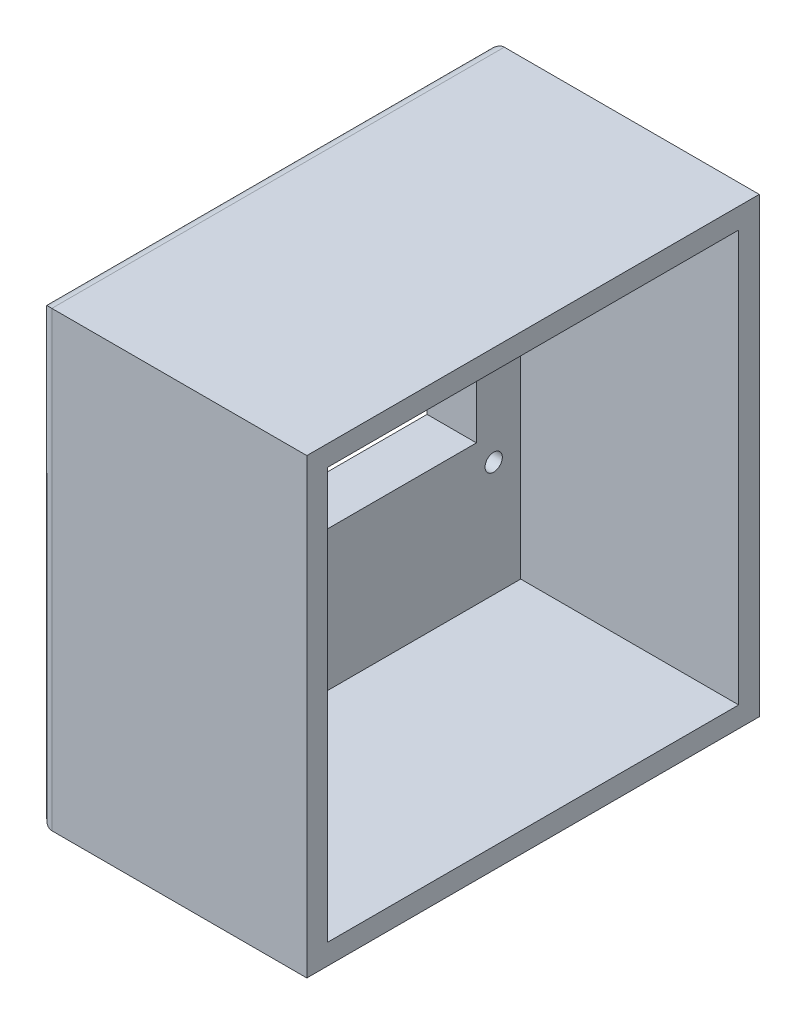
from build123d import *

# Parameters (mm, degrees)
ESBO_O1_W                = 100
ESBO_O1_H                = 100
ESBO_O1_R                = 2.099999731
ESBO_O1_R_2              = 3.499999496
ESBO_O1_R_3              = 3.399999765
RESSALTO_EXTRUS_O1_DEPTH = 12
ESBO_O2_W                = 80
ESBO_O2_H                = 53
CORTE_EXTRUS_O1_DEPTH    = 12
ESBO_O3_W                = 110
ESBO_O3_H                = 110
ESBO_O3_W_2              = 100
ESBO_O3_H_2              = 100
RESSALTO_EXTRUS_O2_DEPTH = 65
FILETE1_R                = 3


with BuildPart() as part:
    # Esboço1 → Ressalto-extrusão1 (new body)
    with BuildSketch(Plane(origin=(0, 0, 0), x_dir=(0, 0, -1), z_dir=(1, 0, 0))):
        with Locations((-414.454548573, 389.240771296)):
            Rectangle(ESBO_O1_W, ESBO_O1_H)
        with Locations((-371.077987612, 432.946200958)):
            Circle(ESBO_O1_R, mode=Mode.SUBTRACT)
        with Locations((-371.024063379, 367.14624515)):
            Circle(ESBO_O1_R, mode=Mode.SUBTRACT)
        with Locations((-458.877958129, 432.87424738)):
            Circle(ESBO_O1_R, mode=Mode.SUBTRACT)
        with Locations((-458.824033895, 367.074291572)):
            Circle(ESBO_O1_R, mode=Mode.SUBTRACT)
        with Locations((-451.165348634, 356.487124133)):
            Circle(ESBO_O1_R_2, mode=Mode.SUBTRACT)
        with Locations((-418.165360481, 356.508431567)):
            Circle(ESBO_O1_R_3, mode=Mode.SUBTRACT)
    extrude(amount=RESSALTO_EXTRUS_O1_DEPTH)

    # Esboço2 → Corte-extrusão1 (cut)
    with BuildSketch(Plane.ZY):
        with Locations((415.220911045, 399.798918519)):
            Rectangle(ESBO_O2_W, ESBO_O2_H)
    extrude(amount=-CORTE_EXTRUS_O1_DEPTH, mode=Mode.SUBTRACT)

    # Esboço3 → Ressalto-extrusão2 (add)
    with BuildSketch(Plane.ZY):
        with Locations((414.454548573, 389.240771296)):
            Rectangle(ESBO_O3_W, ESBO_O3_H)
        with Locations((414.454548573, 389.240771296)):
            Rectangle(ESBO_O3_W_2, ESBO_O3_H_2, mode=Mode.SUBTRACT)
    extrude(amount=-RESSALTO_EXTRUS_O2_DEPTH)

    # Filete1
    filete1_edges = [part.edges().sort_by_distance(p)[0] for p in [
        (0, 444.240771296, 414.454548573),
        (0, 389.240771296, 359.454548573),
        (0, 334.240771296, 414.454548573),
        (0, 389.240771296, 469.454548573),
    ]]
    fillet(filete1_edges, radius=FILETE1_R)


solid = part.part
